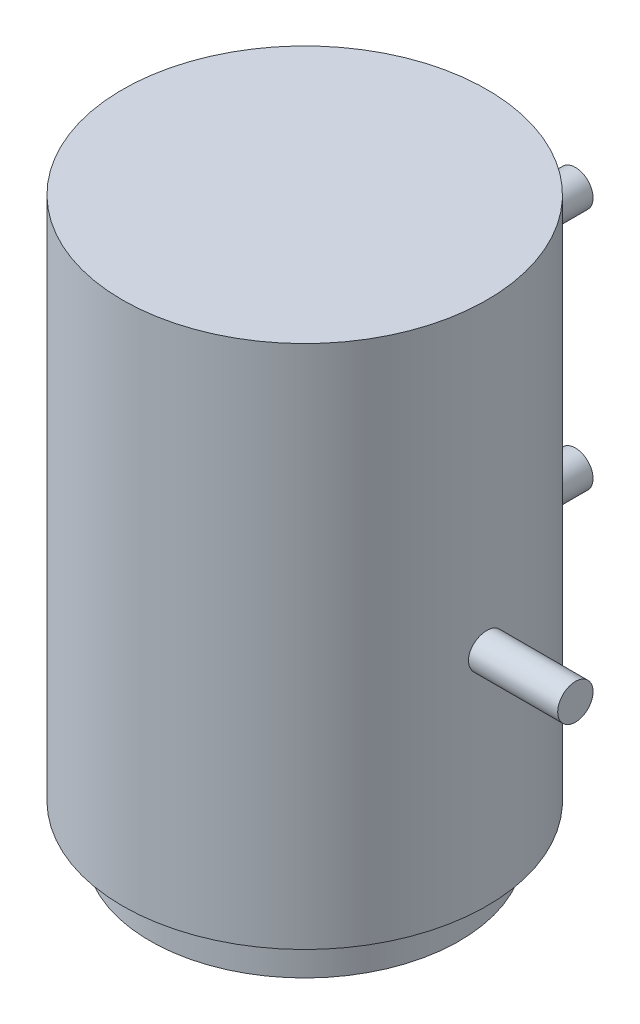
from build123d import *

# Parameters (mm, degrees)
SKETCH1_R                = 16.5
BOSS_EXTRUDE1_DEPTH      = 47.5
SKETCH2_R                = 14
BOSS_EXTRUDE2_DEPTH      = 4
BOSS_EXTRUDE3_DEPTH      = 8
BOSS_EXTRUDE3_DEPTH_BACK = 1
SKETCH4_R                = 1.6
BOSS_EXTRUDE4_DEPTH      = 8
BOSS_EXTRUDE4_DEPTH_BACK = 1
SKETCH5_R                = 1.6


with BuildPart() as part:
    # Sketch1 → Boss-Extrude1 (new body)
    with BuildSketch(Plane(origin=(0, 0, 0), x_dir=(1, 0, 0), z_dir=(0, 1, 0))):
        Circle(SKETCH1_R)
    extrude(amount=BOSS_EXTRUDE1_DEPTH)

    # Sketch2 → Boss-Extrude2 (add)
    with BuildSketch(Plane.XZ):
        Circle(SKETCH2_R)
    extrude(amount=BOSS_EXTRUDE2_DEPTH)

    # Sketch4 → Boss-Extrude3 (add, two sides: drawn at the far end of the back side and taken through both)
    with BuildSketch(Plane(origin=(0, 0, -16.5), x_dir=(-1, 0, 0), z_dir=(0, 0, -1)).offset(-BOSS_EXTRUDE3_DEPTH_BACK)):
        with Locations((0, 35.800460913)):
            Circle(SKETCH4_R)
        with Locations((0, 13.800460913)):
            Circle(SKETCH4_R)
    extrude(amount=BOSS_EXTRUDE3_DEPTH + BOSS_EXTRUDE3_DEPTH_BACK)

    # Sketch5 → Boss-Extrude4 (add, two sides: drawn at the far end of the back side and taken through both)
    with BuildSketch(Plane(origin=(16.5, 0, 0), x_dir=(0, 0, -1), z_dir=(1, 0, 0)).offset(-BOSS_EXTRUDE4_DEPTH_BACK)):
        with Locations((0, 20)):
            Circle(SKETCH5_R)
    extrude(amount=BOSS_EXTRUDE4_DEPTH + BOSS_EXTRUDE4_DEPTH_BACK)


solid = part.part
